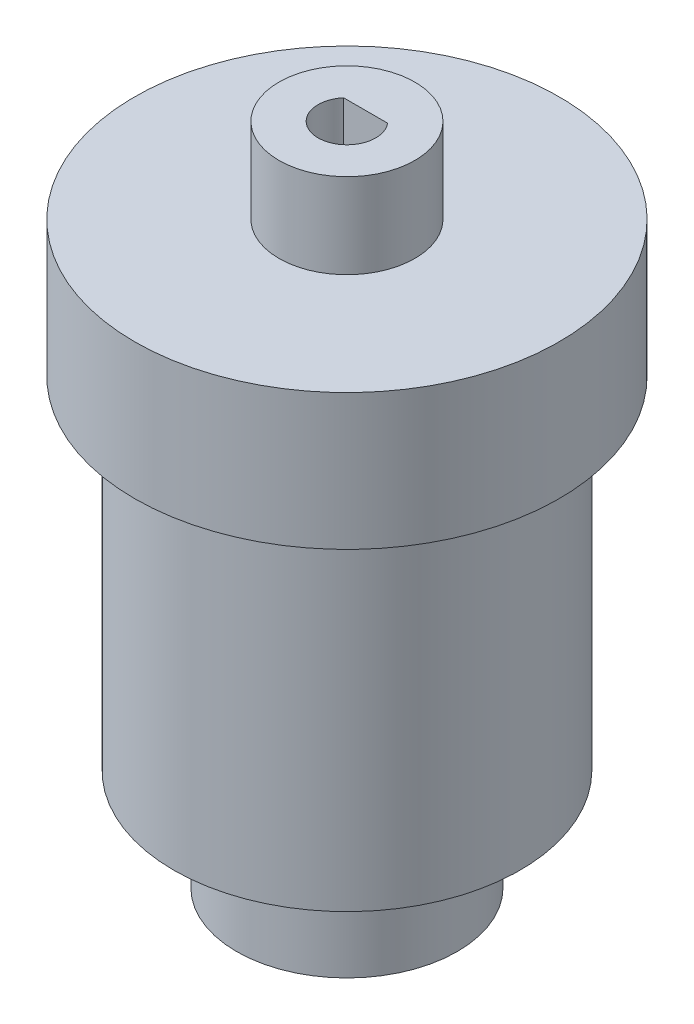
from build123d import *

# Parameters (mm, degrees)
SKETCH1_R           = 10.2
BOSS_EXTRUDE1_DEPTH = 20.1
CUT_EXTRUDE3_DEPTH  = 21.1
SKETCH9_R           = 12.5
BOSS_EXTRUDE3_DEPTH = 8
SKETCH10_R          = 4
BOSS_EXTRUDE4_DEPTH = 5
CUT_EXTRUDE5_DEPTH  = 15
SKETCH12_R          = 6.5
BOSS_EXTRUDE5_DEPTH = 6


with BuildPart() as part:
    # Sketch1 → Boss-Extrude1 (new body)
    with BuildSketch(Plane(origin=(0, 0, 0), x_dir=(1, 0, 0), z_dir=(0, 1, 0))):
        Circle(SKETCH1_R)
    extrude(amount=BOSS_EXTRUDE1_DEPTH)

    # Sketch6 → Cut-Extrude3 (cut, through all)
    with BuildSketch(Plane(origin=(0, 20.1, 0), x_dir=(1, 0, 0), z_dir=(0, 1, 0))):
        Polygon((-3.6, 6.86312611), (3.6, 6.86312611), (5.03591293, 8.870151124), (5.03591293, 10.936036024), (-4.887797844, 10.936036024), (-5.03591293, 8.870151124), align=None)
    extrude(amount=-CUT_EXTRUDE3_DEPTH, mode=Mode.SUBTRACT)

    # Sketch9 → Boss-Extrude3 (add)
    with BuildSketch(Plane(origin=(0, 20.1, 0), x_dir=(1, 0, 0), z_dir=(0, 1, 0))):
        Circle(SKETCH9_R)
    extrude(amount=BOSS_EXTRUDE3_DEPTH)

    # Sketch10 → Boss-Extrude4 (add)
    with BuildSketch(Plane(origin=(0, 28.1, 0), x_dir=(1, 0, 0), z_dir=(0, 1, 0))):
        Circle(SKETCH10_R)
    extrude(amount=BOSS_EXTRUDE4_DEPTH)

    # Sketch11 → Cut-Extrude5 (cut)
    with BuildSketch(Plane(origin=(0, 33.1, 0), x_dir=(1, 0, 0), z_dir=(0, 1, 0))):
        with BuildLine():
            Line((-1.29614814, 1.1), (1.29614814, 1.1))
            ThreePointArc((1.29614814, 1.1), (0, -1.7), (-1.29614814, 1.1))
        make_face()
    extrude(amount=-CUT_EXTRUDE5_DEPTH, mode=Mode.SUBTRACT)

    # Sketch12 → Boss-Extrude5 (add)
    with BuildSketch(Plane.XZ):
        Circle(SKETCH12_R)
    extrude(amount=BOSS_EXTRUDE5_DEPTH)


solid = part.part
